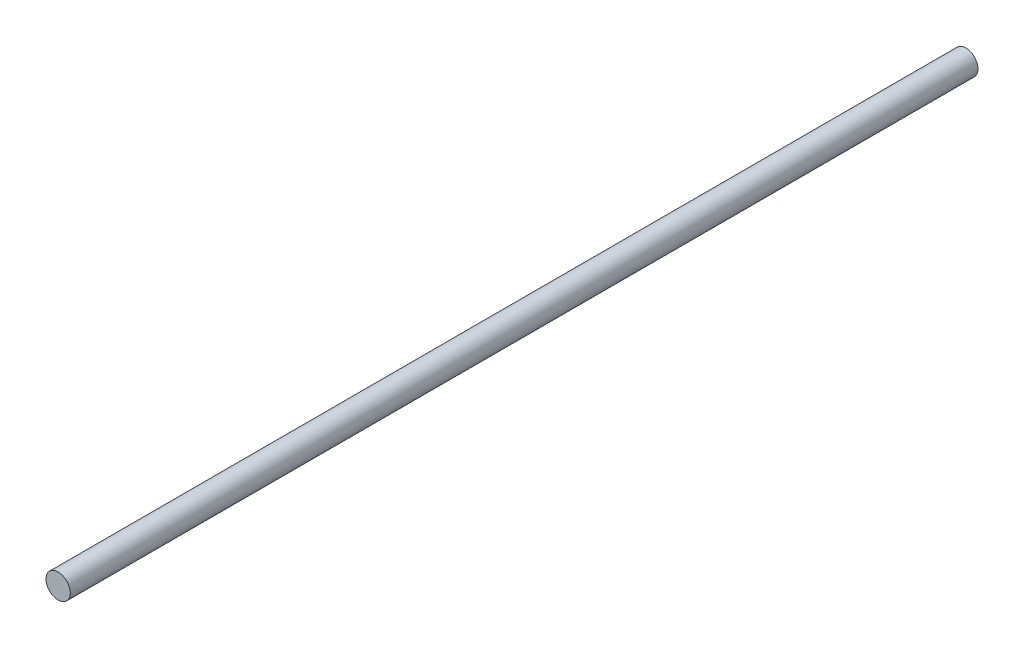
from build123d import *

# Parameters (mm, degrees)
SKETCH1_R           = 2.38125
BOSS_EXTRUDE1_DEPTH = 177.8


with BuildPart() as part:
    # Sketch1 → Boss-Extrude1 (new body)
    with BuildSketch(Plane.XY):
        Circle(SKETCH1_R)
    extrude(amount=BOSS_EXTRUDE1_DEPTH)


solid = part.part
